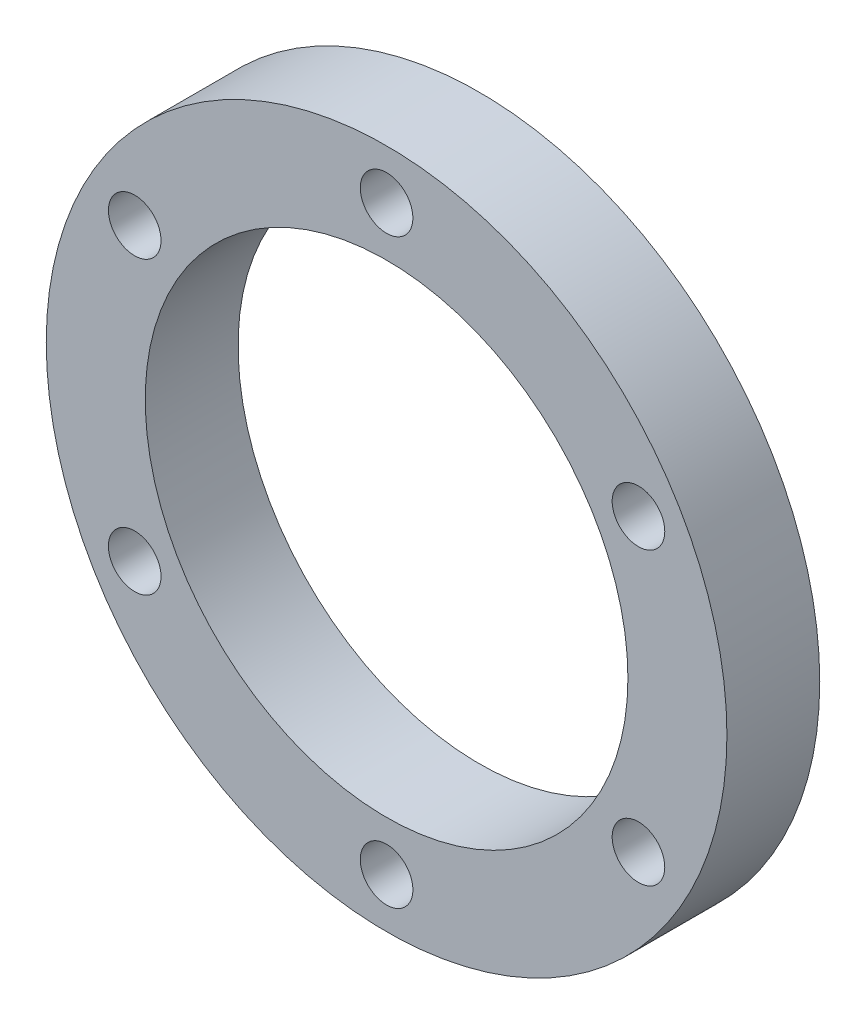
from build123d import *

# Parameters (mm, degrees)
ESQUISSE1_R                  = 55
BOSS_EXTRU_1_DEPTH           = 15
TROU_TARAUD_M101_D           = 8.5
R_P_TITION_CIRCULAIRE1_COUNT = 6
ESQUISSE4_R                  = 39
ENL_V_MAT_EXTRU_1_DEPTH      = 16


with BuildPart() as part:
    # Esquisse1 → Boss.-Extru.1 (new body)
    with BuildSketch(Plane.XY):
        Circle(ESQUISSE1_R)
    extrude(amount=BOSS_EXTRU_1_DEPTH)

    # Trou taraudé M101 (through all)
    with Locations(Plane.XY.offset(15)):
        with Locations((0, 47)):
            trou_taraud_m101 = Hole(TROU_TARAUD_M101_D / 2)

    # Répétition circulaire1: Trou taraudé M101 ×6 about axis
    r_p_tition_circulaire1_axis = Axis((0, 0, 0), (0, 0, 1))
    for i in range(1, R_P_TITION_CIRCULAIRE1_COUNT):
        add(trou_taraud_m101.rotate(r_p_tition_circulaire1_axis, i * 360 / R_P_TITION_CIRCULAIRE1_COUNT), mode=Mode.SUBTRACT)

    # Esquisse4 → Enlèv. mat.-Extru.1 (cut, through all)
    with BuildSketch(Plane.XY.offset(15)):
        Circle(ESQUISSE4_R)
    extrude(amount=-ENL_V_MAT_EXTRU_1_DEPTH, mode=Mode.SUBTRACT)


solid = part.part
